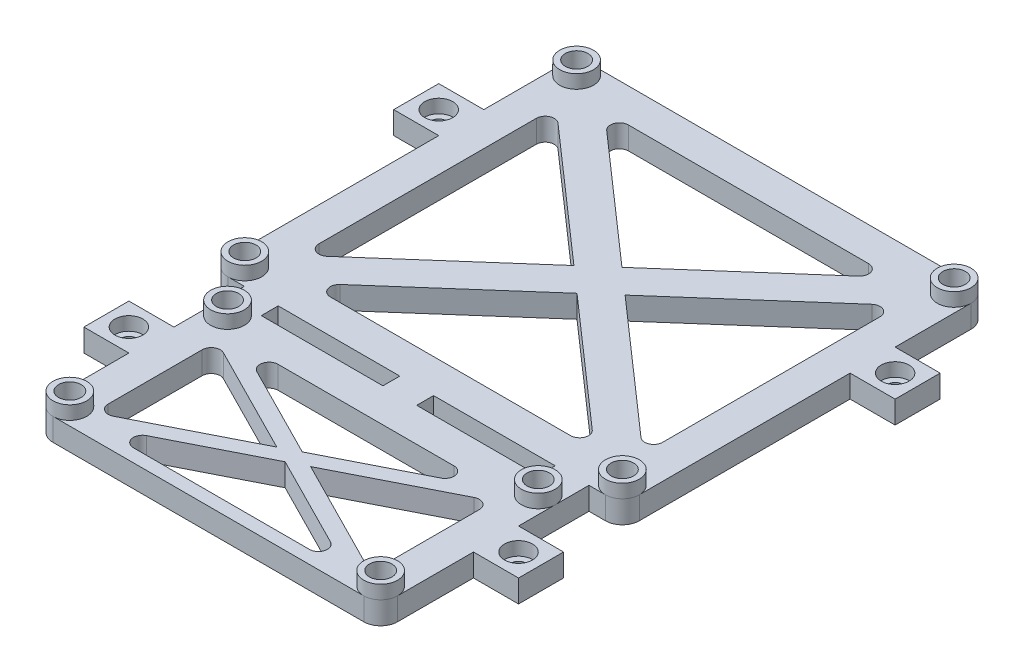
from build123d import *

# Parameters (mm, degrees)
SKETCH2_R                      = 2.5000000000000027
BOSS_EXTRUDE2_DEPTH            = 5
SKETCH3_R                      = 3.750000000000007
SKETCH3_R_2                    = 2.5000000000000027
SKETCH3_R_3                    = 3.7500000000000036
SKETCH3_R_4                    = 3.7500000000000138
SKETCH3_R_5                    = 3.7499999999999916
BOSS_EXTRUDE3_DEPTH            = 3
FILLET1_R                      = 3.75
BOSS_EXTRUDE4_DEPTH            = 5
CBORE_FOR_M3_SHCS1_D           = 3.4
CBORE_FOR_M3_SHCS1_CBORE_D     = 6.2
CBORE_FOR_M3_SHCS1_CBORE_DEPTH = 3
SKETCH8_R                      = 2.5000000000000027
BOSS_EXTRUDE5_DEPTH            = 4
FILLET2_R                      = 2


with BuildPart() as part:
    # Sketch2 → Boss-Extrude2 (new body)
    with BuildSketch(Plane(origin=(0, 0, 0), x_dir=(1, 0, 0), z_dir=(0, 1, 0))):
        Polygon((45.660000000000004, 40.58000000000002), (-45.65999999999999, 40.58000000000002), (-45.65999999999999, -40.580000000000005), (-38.24999999999999, -40.580000000000005), (-38.25000000000001, -48.07999999999986), (-38.25000000000001, -86.82999999999993), (38.25000000000002, -86.82999999999993), (38.25000000000001, -48.0799999999999), (38.25000000000002, -40.57999999999999), (45.660000000000004, -40.57999999999999), align=None)
        with Locations(Location((-41.90999999999999, 36.83000000000001, 0), (0, 0, 270))):
            Circle(SKETCH2_R, mode=Mode.SUBTRACT)
        with Locations(Location((41.910000000000004, 36.83000000000001, 0), (0, 0, 270))):
            Circle(SKETCH2_R, mode=Mode.SUBTRACT)
        with Locations(Location((-41.90999999999999, -36.82999999999999, 0), (0, 0, 270))):
            Circle(SKETCH2_R, mode=Mode.SUBTRACT)
        with Locations(Location((41.910000000000004, -36.82999999999999, 0), (0, 0, 270))):
            Circle(SKETCH2_R, mode=Mode.SUBTRACT)
        with Locations(Location((-34.50000000000001, -48.07999999999986, 0), (0, 0, 270))):
            Circle(SKETCH2_R, mode=Mode.SUBTRACT)
        with Locations(Location((-34.49999999999999, -83.0799999999999, 0), (0, 0, 270))):
            Circle(SKETCH2_R, mode=Mode.SUBTRACT)
        with Locations(Location((34.49999999999999, -83.0799999999999, 0), (0, 0, 270))):
            Circle(SKETCH2_R, mode=Mode.SUBTRACT)
        with Locations(Location((34.50000000000001, -48.0799999999999, 0), (0, 0, 270))):
            Circle(SKETCH2_R, mode=Mode.SUBTRACT)
        Polygon((38.16, -28.542299400797987), (5.680831716333313, 2.429e-14), (38.16, 28.542299400798022), align=None, mode=Mode.SUBTRACT)
        Polygon((-38.15999999999998, -28.54229940079798), (-38.15999999999999, 28.54229940079801), (-5.680831716333299, 1.041e-14), align=None, mode=Mode.SUBTRACT)
        Polygon((31.96192690435635, 33.08000000000001), (6.94e-15, 4.992246053747464), (-31.96192690435633, 33.08000000000001), align=None, mode=Mode.SUBTRACT)
        Polygon((31.96192690435635, -33.079999999999984), (7.81e-15, -4.992246053747436), (-31.961926904356336, -33.079999999999984), align=None, mode=Mode.SUBTRACT)
        Polygon((-30.749999999999986, -44.32999999999987), (-3.75, -44.32999999999987), (-3.749999999999986, -40.58), (-30.74999999999999, -40.580000000000005), align=None, mode=Mode.SUBTRACT)
        Polygon((30.75, -81.57832850736624), (30.750000000000004, -54.18702415953998), (3.7500000000000004, -67.88267633345322), align=None, mode=Mode.SUBTRACT)
        Polygon((30.750000000000004, -44.32999999999987), (30.750000000000018, -40.57999999999999), (3.7500000000000138, -40.58), (3.750000000000019, -44.32999999999987), align=None, mode=Mode.SUBTRACT)
        Polygon((-27.896704771665014, -83.9353526669063), (27.896704771665014, -83.9353526669063), (0, -69.78485024649659), align=None, mode=Mode.SUBTRACT)
        Polygon((-27.896704771665025, -51.82999999999982), (-2.8e-16, -65.98050242040974), (27.896704771665025, -51.82999999999982), align=None, mode=Mode.SUBTRACT)
        Polygon((-30.750000000000004, -54.18702415953998), (-3.749999999999999, -67.88267633345322), (-30.75, -81.57832850736624), align=None, mode=Mode.SUBTRACT)
    extrude(amount=BOSS_EXTRUDE2_DEPTH)

    # Sketch3 → Boss-Extrude3 (add)
    # profile 1 of 8: a face of its own
    with BuildSketch(Plane(origin=(0, 5, 0), x_dir=(1, 0, 0), z_dir=(0, 1, 0))):
        with Locations(Location((-41.90999999999999, 36.83000000000001, 0), (0, 0, 90))):
            Circle(SKETCH3_R)
        with Locations(Location((-41.90999999999999, 36.83000000000001, 0), (0, 0, 270))):
            Circle(SKETCH3_R_2, mode=Mode.SUBTRACT)
    # profile 2 of 8: a face of its own
    with BuildSketch(Plane(origin=(0, 5, 0), x_dir=(1, 0, 0), z_dir=(0, 1, 0))):
        with Locations(Location((41.910000000000004, 36.83000000000001, 0), (0, 0, 90))):
            Circle(SKETCH3_R)
        with Locations(Location((41.910000000000004, 36.83000000000001, 0), (0, 0, 270))):
            Circle(SKETCH3_R_2, mode=Mode.SUBTRACT)
    # profile 3 of 8: a face of its own
    with BuildSketch(Plane(origin=(0, 5, 0), x_dir=(1, 0, 0), z_dir=(0, 1, 0))):
        with Locations(Location((41.910000000000004, -36.82999999999999, 0), (0, 0, 270))):
            Circle(SKETCH3_R)
        with Locations(Location((41.910000000000004, -36.82999999999999, 0), (0, 0, 270))):
            Circle(SKETCH3_R_2, mode=Mode.SUBTRACT)
    # profile 4 of 8: a face of its own
    with BuildSketch(Plane(origin=(0, 5, 0), x_dir=(1, 0, 0), z_dir=(0, 1, 0))):
        with Locations(Location((-41.90999999999999, -36.82999999999999, 0), (0, 0, 270))):
            Circle(SKETCH3_R)
        with Locations(Location((-41.90999999999999, -36.82999999999999, 0), (0, 0, 270))):
            Circle(SKETCH3_R_2, mode=Mode.SUBTRACT)
    # profile 5 of 8: a face of its own
    with BuildSketch(Plane(origin=(0, 5, 0), x_dir=(1, 0, 0), z_dir=(0, 1, 0))):
        with Locations(Location((-34.50000000000001, -48.07999999999986, 0), (0, 0, 180))):
            Circle(SKETCH3_R_3)
        with Locations(Location((-34.50000000000001, -48.07999999999986, 0), (0, 0, 270))):
            Circle(SKETCH3_R_2, mode=Mode.SUBTRACT)
    # profile 6 of 8: a face of its own
    with BuildSketch(Plane(origin=(0, 5, 0), x_dir=(1, 0, 0), z_dir=(0, 1, 0))):
        with Locations(Location((-34.49999999999999, -83.0799999999999, 0), (0, 0, 270))):
            Circle(SKETCH3_R_3)
        with Locations(Location((-34.49999999999999, -83.0799999999999, 0), (0, 0, 270))):
            Circle(SKETCH3_R_2, mode=Mode.SUBTRACT)
    # profile 7 of 8: a face of its own
    with BuildSketch(Plane(origin=(0, 5, 0), x_dir=(1, 0, 0), z_dir=(0, 1, 0))):
        with Locations(Location((34.49999999999999, -83.0799999999999, 0), (0, 0, 270))):
            Circle(SKETCH3_R_4)
        with Locations(Location((34.49999999999999, -83.0799999999999, 0), (0, 0, 270))):
            Circle(SKETCH3_R_2, mode=Mode.SUBTRACT)
    # profile 8 of 8: a face of its own
    with BuildSketch(Plane(origin=(0, 5, 0), x_dir=(1, 0, 0), z_dir=(0, 1, 0))):
        with Locations((34.50000000000001, -48.0799999999999)):
            Circle(SKETCH3_R_5)
        with Locations(Location((34.50000000000001, -48.0799999999999, 0), (0, 0, 270))):
            Circle(SKETCH3_R_2, mode=Mode.SUBTRACT)
    extrude(amount=BOSS_EXTRUDE3_DEPTH)

    # Fillet1
    fillet1_edges = [part.edges().sort_by_distance(p)[0] for p in [
        (-45.65999999999999, 2.5, -40.58000000000002),
        (38.25000000000002, 2.5, 86.82999999999993),
        (-38.25000000000001, 2.5, 86.82999999999993),
        (-45.65999999999999, 2.5, 40.580000000000005),
        (45.660000000000004, 2.5, 40.57999999999999),
        (45.660000000000004, 2.5, -40.58000000000002),
    ]]
    fillet(fillet1_edges, radius=FILLET1_R)

    # Sketch4 → Boss-Extrude4 (add)
    with BuildSketch(Plane.XZ):
        Polygon((-45.65999999999999, -19.975), (-55.66, -19.975), (-55.66, -9.975000000000001), (-45.65999999999999, -9.975000000000003), align=None)
        Polygon((45.660000000000004, -19.975), (55.66000000000001, -19.975), (55.660000000000004, -9.974999999999998), (45.660000000000004, -9.975000000000001), align=None)
        Polygon((-38.25000000000007, 56.224999999999994), (-48.25000000000008, 56.225), (-48.25000000000008, 66.22500000000001), (-38.25000000000007, 66.22500000000001), align=None)
        Polygon((38.25000000000002, 66.22500000000001), (48.250000000000014, 66.22500000000001), (48.25000000000002, 56.224999999999994), (38.25000000000002, 56.224999999999994), align=None)
    extrude(amount=-BOSS_EXTRUDE4_DEPTH)

    # CBORE for M3 SHCS1 (through all)
    with Locations(Plane(origin=(0, 5, 0), x_dir=(1, 0, 0), z_dir=(0, 1, 0))):
        with Locations((50.66, 14.975), (-50.66, 14.975), (-43.25, -61.225), (43.25, -61.225)):
            CounterBoreHole(CBORE_FOR_M3_SHCS1_D / 2, CBORE_FOR_M3_SHCS1_CBORE_D / 2, CBORE_FOR_M3_SHCS1_CBORE_DEPTH)

    # Sketch8 → Boss-Extrude5 (add)
    with BuildSketch(Plane.XZ):
        with Locations(Location((-34.49999999999999, 83.0799999999999, 0), (0, 0, 270))):
            Circle(SKETCH8_R)
        with Locations(Location((34.49999999999999, 83.0799999999999, 0), (0, 0, 270))):
            Circle(SKETCH8_R)
        with Locations(Location((34.50000000000001, 48.0799999999999, 0), (0, 0, 270))):
            Circle(SKETCH8_R)
        with Locations(Location((41.910000000000004, 36.82999999999999, 0), (0, 0, 270))):
            Circle(SKETCH8_R)
        with Locations(Location((41.910000000000004, -36.83000000000001, 0), (0, 0, 270))):
            Circle(SKETCH8_R)
        with Locations(Location((-41.90999999999999, -36.83000000000001, 0), (0, 0, 270))):
            Circle(SKETCH8_R)
        with Locations(Location((-41.90999999999999, 36.82999999999999, 0), (0, 0, 270))):
            Circle(SKETCH8_R)
        with Locations(Location((-34.50000000000001, 48.07999999999986, 0), (0, 0, 270))):
            Circle(SKETCH8_R)
    extrude(amount=-BOSS_EXTRUDE5_DEPTH)

    # Fillet2
    fillet2_edges = [part.edges().sort_by_distance(p)[0] for p in [
        (27.896704771665025, 2.5, 51.82999999999982),
        (-27.896704771665025, 2.5, 51.82999999999982),
        (-27.896704771665014, 2.5, 83.9353526669063),
        (27.896704771665014, 2.5, 83.9353526669063),
        (-30.750000000000004, 2.5, 54.18702415953998),
        (-30.75, 2.5, 81.57832850736624),
        (-31.961926904356336, 2.5, 33.079999999999984),
        (31.96192690435635, 2.5, 33.079999999999984),
        (31.96192690435635, 2.5, -33.08000000000001),
        (-31.96192690435633, 2.5, -33.08000000000001),
        (-38.15999999999999, 2.5, -28.54229940079801),
        (-38.15999999999998, 2.5, 28.54229940079798),
        (38.16, 2.5, -28.542299400798022),
        (38.16, 2.5, 28.542299400797987),
        (30.75, 2.5, 81.57832850736624),
        (30.750000000000004, 2.5, 54.18702415953998),
    ]]
    fillet(fillet2_edges, radius=FILLET2_R)


solid = part.part
